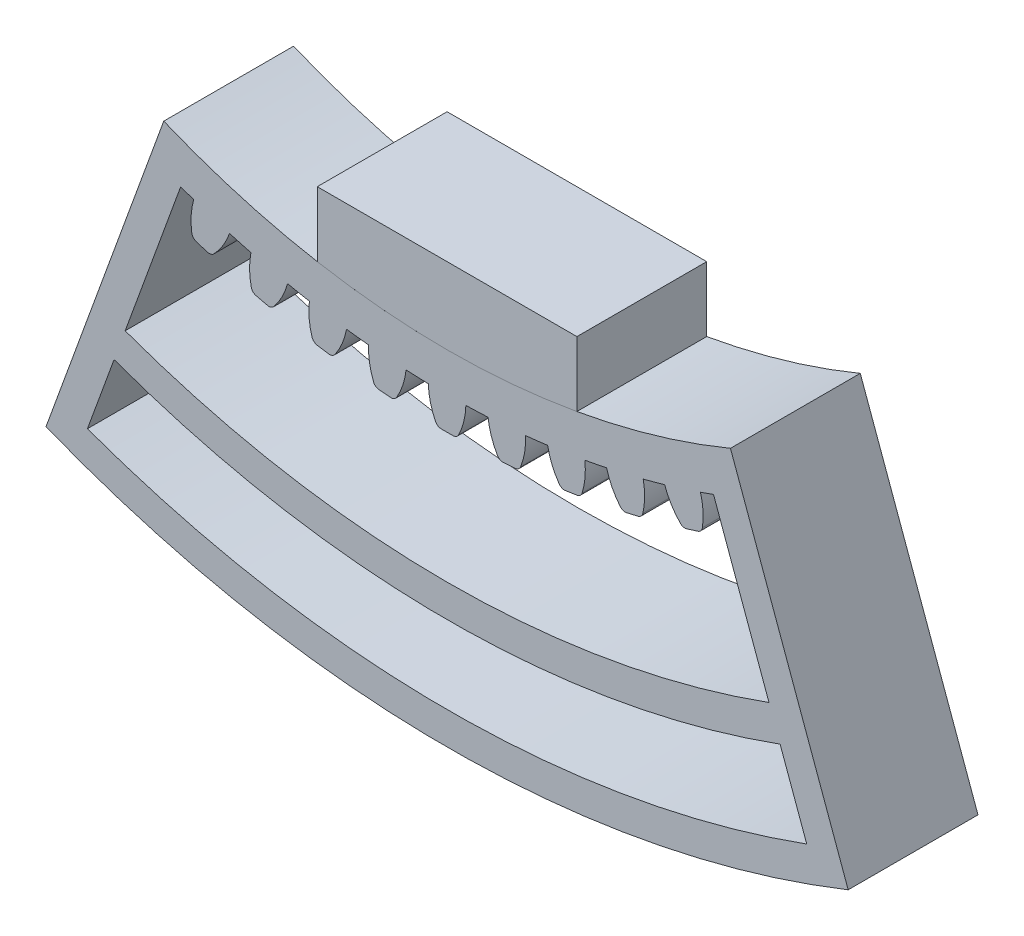
from build123d import *

# Parameters (mm, degrees)
BOSS_EXTRU_1_DEPTH                  = 10
BOSS_EXTRU_3_DEPTH                  = 20
CONG_2_R                            = 1
R_P_TITION_CIRCULAIRE11_COUNT       = 5
R_P_TITION_CIRCULAIRE11_ANGLE       = 17.6
CONG_2_OF_R_P_TITION_CIRCULAIRE11_R = 1
R_P_TITION_CIRCULAIRE12_COUNT       = 5
R_P_TITION_CIRCULAIRE12_ANGLE       = 17.6
CONG_2_OF_R_P_TITION_CIRCULAIRE12_R = 1
ESQUISSE3_W                         = 40
ESQUISSE3_H                         = 10
BOSS_EXTRU_5_DEPTH                  = 20
ENL_V_MAT_EXTRU_1_DEPTH             = 21.0000001


with BuildPart() as part:
    # Esquisse1 → Boss.-Extru.1 (new body, symmetric)
    with BuildSketch(Plane.XY):
        with BuildLine():
            Line((-83.5, -144.626242432), (-57, -98.726896031))
            ThreePointArc((-57, -98.726896031), (0, -114), (57, -98.726896031))
            Line((57, -98.726896031), (83.5, -144.626242432))
            ThreePointArc((83.5, -144.626242432), (0, -167), (-83.5, -144.626242432))
        make_face()
        with BuildLine():
            Line((-49.592920782, -136.255430014), (-41.042417199, -112.763114494))
            ThreePointArc((-41.042417199, -112.763114494), (0, -120), (41.042417199, -112.763114494))
            Line((41.042417199, -112.763114494), (49.592920782, -136.255430014))
            ThreePointArc((49.592920782, -136.255430014), (0, -145), (-49.592920782, -136.255430014))
        make_face(mode=Mode.SUBTRACT)
        with BuildLine():
            Line((51.303021499, -140.953893118), (55.407263219, -152.230204567))
            ThreePointArc((55.407263219, -152.230204567), (0, -162), (-55.407263219, -152.230204567))
            Line((-55.407263219, -152.230204567), (-51.303021499, -140.953893118))
            ThreePointArc((-51.303021499, -140.953893118), (0, -150), (51.303021499, -140.953893118))
        make_face(mode=Mode.SUBTRACT)
    extrude(amount=BOSS_EXTRU_1_DEPTH, both=True)

    # Esquisse2 → Boss.-Extru.3 (add)
    with BuildSketch(Plane.XY.offset(10)):
        with BuildLine():
            ThreePointArc((-2.89556925, -119.965060241), (-2.5, -122.561947103), (-1.5, -124.990999676))
            ThreePointArc((-1.5, -124.990999676), (0, -125), (1.5, -124.990999676))
            ThreePointArc((1.5, -124.990999676), (2.5, -122.561947103), (2.89556925, -119.965060241))
            ThreePointArc((2.89556925, -119.965060241), (0, -120), (-2.89556925, -119.965060241))
        make_face()
    boss_extru_3 = extrude(amount=-BOSS_EXTRU_3_DEPTH)

    # Congé2
    cong_2_edges = [part.edges().sort_by_distance(p)[0] for p in [
        (1.5, -124.990999676, 0),
        (-1.5, -124.990999676, 0),
    ]]
    fillet(cong_2_edges, radius=CONG_2_R)

    # Répétition circulaire11: Boss.-Extru.3 ×5 about axis
    r_p_tition_circulaire11_axis = Axis((0, 0, 0), (0, 0, -1))
    for i in range(1, R_P_TITION_CIRCULAIRE11_COUNT):
        add(boss_extru_3.rotate(r_p_tition_circulaire11_axis, i * R_P_TITION_CIRCULAIRE11_ANGLE / (R_P_TITION_CIRCULAIRE11_COUNT - 1)))

    # Congé2 of Répétition circulaire11
    cong_2_of_r_p_tition_circulaire11_edges = [part.edges().sort_by_distance(p)[0] for p in [
        (-8.093608891, -124.737698773, 0),
        (-11.084767148, -124.507541688, 0),
        (-17.639510041, -123.74913206, 0),
        (-20.604195186, -123.290174551, 0),
        (-27.081435178, -122.031126639, 0),
        (-30.002171886, -121.346074028, 0),
        (-36.363728915, -119.593809285, 0),
        (-39.223300919, -118.686699613, 0),
    ]]
    fillet(cong_2_of_r_p_tition_circulaire11_edges, radius=CONG_2_OF_R_P_TITION_CIRCULAIRE11_R)

    # Répétition circulaire12: Boss.-Extru.3 ×5 about axis
    r_p_tition_circulaire12_axis = Axis((0, 0, 0), (0, 0, 1))
    for i in range(1, R_P_TITION_CIRCULAIRE12_COUNT):
        add(boss_extru_3.rotate(r_p_tition_circulaire12_axis, i * R_P_TITION_CIRCULAIRE12_ANGLE / (R_P_TITION_CIRCULAIRE12_COUNT - 1)))

    # Congé2 of Répétition circulaire12
    cong_2_of_r_p_tition_circulaire12_edges = [part.edges().sort_by_distance(p)[0] for p in [
        (11.084767148, -124.507541688, 0),
        (8.093608891, -124.737698773, 0),
        (20.604195186, -123.290174551, 0),
        (17.639510041, -123.74913206, 0),
        (30.002171886, -121.346074028, 0),
        (27.081435178, -122.031126639, 0),
        (39.223300919, -118.686699613, 0),
        (36.363728915, -119.593809285, 0),
    ]]
    fillet(cong_2_of_r_p_tition_circulaire12_edges, radius=CONG_2_OF_R_P_TITION_CIRCULAIRE12_R)

    # Esquisse4 → Enlèv. mat.-Extru.1 (cut, through all)
    with BuildSketch(Plane(origin=(0, 0, -10), x_dir=(-1, 0, 0), z_dir=(0, 0, -1))):
        with BuildLine():
            Line((43.651239182, -105.311771982), (61.79022099, -155.148214911))
            ThreePointArc((61.79022099, -155.148214911), (72.835362668, -150.279772242), (83.5, -144.626242432))
            Line((83.5, -144.626242432), (57, -98.726896031))
            ThreePointArc((57, -98.726896031), (50.433204687, -102.237428885), (43.651239182, -105.311771982))
        make_face()
    enl_v_mat_extru_1 = extrude(amount=-ENL_V_MAT_EXTRU_1_DEPTH, mode=Mode.SUBTRACT)

    # Symétrie1: Enlèv. mat.-Extru.1 across plane
    add(enl_v_mat_extru_1.mirror(Plane(origin=(0, 0, 0), x_dir=(0, 0, 1), z_dir=(1, 0, 0))), mode=Mode.SUBTRACT)


with BuildPart() as body_2:
    # Esquisse3 → Boss.-Extru.5 (new body)
    with BuildSketch(Plane.XY.offset(10)):
        with Locations((0, -107.231902773)):
            Rectangle(ESQUISSE3_W, ESQUISSE3_H)
        with BuildLine():
            Line((20, -112.231902773), (-20, -112.231902773))
            ThreePointArc((-20, -112.231902773), (0, -114), (20, -112.231902773))
        make_face()
    extrude(amount=-BOSS_EXTRU_5_DEPTH)


solid = Compound([part.part, body_2.part])
